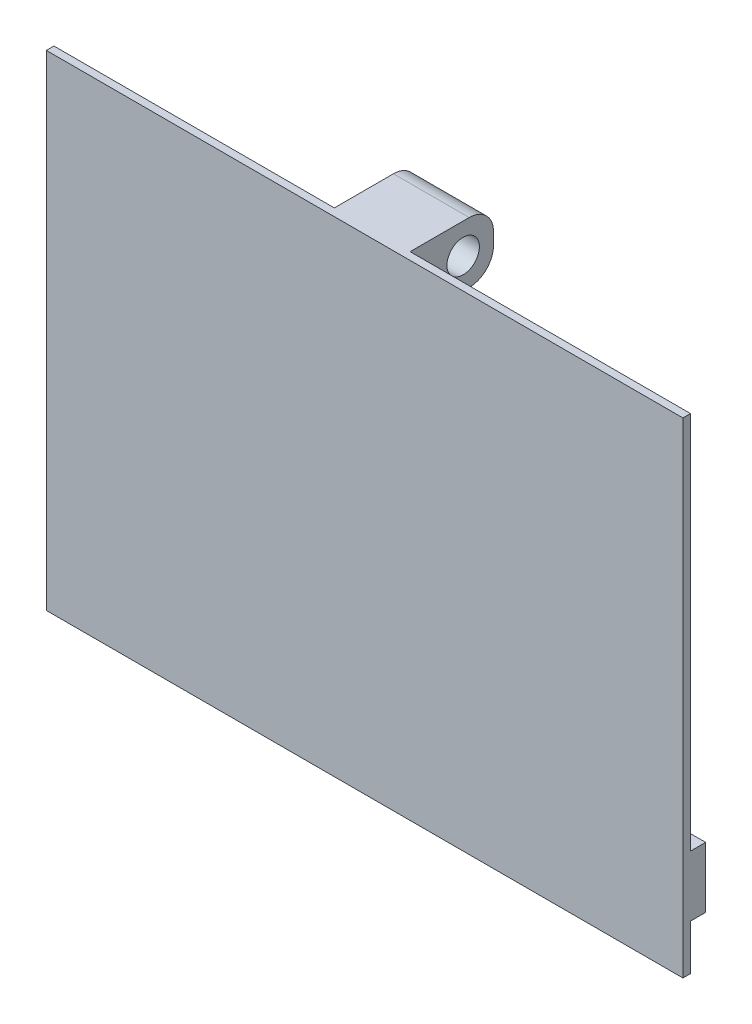
from build123d import *

# Parameters (mm, degrees)
SKETCH1_W                = 66.675
SKETCH1_H                = 50.8
BOSS_EXTRUDE1_DEPTH      = 0.79375
BOSS_EXTRUDE2_DEPTH      = 3.96875
M3_CLEARANCE_HOLE2_D     = 3.4
M3_CLEARANCE_HOLE2_DEPTH = 6.35
M3_CLEARANCE_HOLE2_TIP   = 1.021463052
SKETCH11_W               = 66.675
SKETCH11_H               = 6.35
BOSS_EXTRUDE3_DEPTH      = 1.5875


with BuildPart() as part:
    # Sketch1 → Boss-Extrude1 (new body)
    with BuildSketch(Plane.XY):
        Rectangle(SKETCH1_W, SKETCH1_H)
    extrude(amount=BOSS_EXTRUDE1_DEPTH)

    # Sketch3 → Boss-Extrude2 (add, symmetric)
    with BuildSketch(Plane(origin=(0, 0, 0), x_dir=(0, 0, -1), z_dir=(1, 0, 0))):
        with BuildLine():
            Line((0, 25.4), (6.19125, 25.4))
            ThreePointArc((6.19125, 25.4), (7.987301224, 24.656051224), (8.73125, 22.86))
            Line((8.73125, 22.86), (8.73125, 21.59))
            ThreePointArc((8.73125, 21.59), (7.987301224, 19.793948776), (6.19125, 19.05))
            Line((6.19125, 19.05), (0, 19.05))
            Line((0, 19.05), (0, 25.4))
        make_face()
    extrude(amount=BOSS_EXTRUDE2_DEPTH, both=True)

    # Sketch8 → M3 Clearance Hole1 (revolve, cut)
    with BuildSketch(Plane(origin=(0, 22.225, -5.55625), x_dir=(0, 0, -1), z_dir=(0, 1, 0))):
        Polygon((0, 0), (0, 7.371463052), (1.7, 6.35), (1.7, 0), align=None)
    revolve(axis=Axis((6.35, 22.225, -5.55625), (-1, 0, 0)), mode=Mode.SUBTRACT)

    # M3 Clearance Hole2
    with Locations(Plane.ZY):
        with Locations((-5.55625, 22.225)):
            Hole(M3_CLEARANCE_HOLE2_D / 2, depth=M3_CLEARANCE_HOLE2_DEPTH)
            with Locations((0, 0, -(M3_CLEARANCE_HOLE2_DEPTH + M3_CLEARANCE_HOLE2_TIP / 2))):  # 118° drill point
                Cone(0, M3_CLEARANCE_HOLE2_D / 2, M3_CLEARANCE_HOLE2_TIP, mode=Mode.SUBTRACT)

    # Sketch11 → Boss-Extrude3 (add)
    with BuildSketch(Plane(origin=(0, 0, 0), x_dir=(-1, 0, 0), z_dir=(0, 0, -1))):
        with Locations((0, -17.4625)):
            Rectangle(SKETCH11_W, SKETCH11_H)
    extrude(amount=BOSS_EXTRUDE3_DEPTH)


solid = part.part
